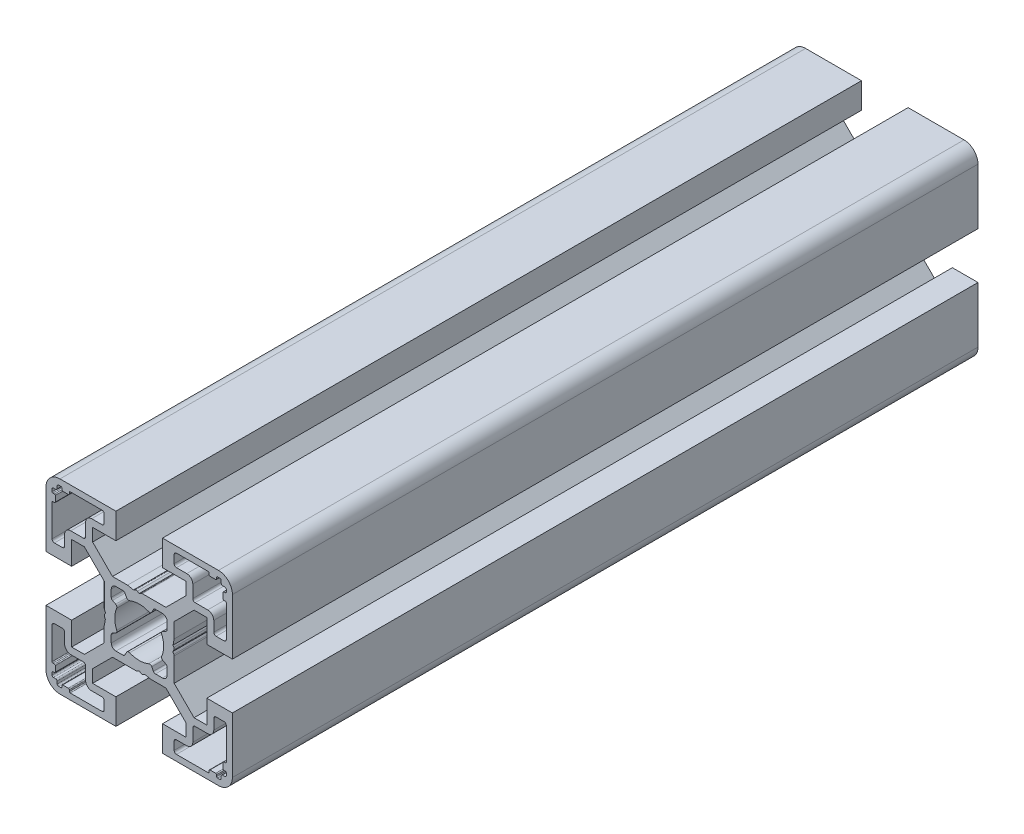
from build123d import *

# Parameters (mm, degrees)
BOSS_EXTRUDE1_DEPTH = 160


with BuildPart() as part:
    # Sketch1 → Boss-Extrude1 (new body)
    with BuildSketch(Plane.XY):
        with BuildLine():
            Line((-11.767766953, -10), (-14.5, -10))
            Line((-14.5, -10), (-14.5, -5))
            Line((-14.5, -5), (-20, -5))
            Line((-20, -5), (-20, -17))
            ThreePointArc((-20, -17), (-19.121320344, -19.121320344), (-17, -20))
            Line((-17, -20), (-5, -20))
            Line((-5, -20), (-5, -14.5))
            Line((-5, -14.5), (-10, -14.5))
            Line((-10, -14.5), (-10, -11.767766953))
            Line((-10, -11.767766953), (-5.732233047, -7.5))
            Line((-5.732233047, -7.5), (-0.653589838, -7.5))
            ThreePointArc((-0.653589838, -7.5), (-0.524180316, -7.482962913), (-0.403589838, -7.433012702))
            Line((-0.403589838, -7.433012702), (0, -7.2))
            Line((0, -7.2), (0.403589838, -7.433012702))
            ThreePointArc((0.403589838, -7.433012702), (0.653589838, -7.5), (0.903589838, -7.433012702))
            Line((0.903589838, -7.433012702), (1.218885629, -7.250976592))
            Line((1.218885629, -7.250976592), (2.5, -7.5))
            Line((2.5, -7.5), (5.732233047, -7.5))
            Line((5.732233047, -7.5), (10, -11.767766953))
            Line((10, -11.767766953), (10, -14.5))
            Line((10, -14.5), (5, -14.5))
            Line((5, -14.5), (5, -20))
            Line((5, -20), (17, -20))
            ThreePointArc((17, -20), (19.121320344, -19.121320344), (20, -17))
            Line((20, -17), (20, -5))
            Line((20, -5), (14.5, -5))
            Line((14.5, -5), (14.5, -10))
            Line((14.5, -10), (11.767766953, -10))
            Line((11.767766953, -10), (7.5, -5.732233047))
            Line((7.5, -5.732233047), (7.5, -0.653589838))
            ThreePointArc((7.5, -0.653589838), (7.482962913, -0.524180316), (7.433012702, -0.403589838))
            Line((7.433012702, -0.403589838), (7.2, 0))
            Line((7.2, 0), (7.433012702, 0.403589838))
            ThreePointArc((7.433012702, 0.403589838), (7.5, 0.653589838), (7.433012702, 0.903589838))
            Line((7.433012702, 0.903589838), (7.250976592, 1.218885629))
            Line((7.250976592, 1.218885629), (7.5, 2.5))
            Line((7.5, 2.5), (7.5, 5.732233047))
            Line((7.5, 5.732233047), (11.767766953, 10))
            Line((11.767766953, 10), (14.5, 10))
            Line((14.5, 10), (14.5, 5))
            Line((14.5, 5), (20, 5))
            Line((20, 5), (20, 17))
            ThreePointArc((20, 17), (19.121320344, 19.121320344), (17, 20))
            Line((17, 20), (5, 20))
            Line((5, 20), (5, 14.5))
            Line((5, 14.5), (10, 14.5))
            Line((10, 14.5), (10, 11.767766953))
            Line((10, 11.767766953), (5.732233047, 7.5))
            Line((5.732233047, 7.5), (0.653589838, 7.5))
            ThreePointArc((0.653589838, 7.5), (0.524180316, 7.482962913), (0.403589838, 7.433012702))
            Line((0.403589838, 7.433012702), (0, 7.2))
            Line((0, 7.2), (-0.403589838, 7.433012702))
            ThreePointArc((-0.403589838, 7.433012702), (-0.653589838, 7.5), (-0.903589838, 7.433012702))
            Line((-0.903589838, 7.433012702), (-1.218885629, 7.250976592))
            Line((-1.218885629, 7.250976592), (-2.5, 7.5))
            Line((-2.5, 7.5), (-5.732233047, 7.5))
            Line((-5.732233047, 7.5), (-10, 11.767766953))
            Line((-10, 11.767766953), (-10, 14.5))
            Line((-10, 14.5), (-5, 14.5))
            Line((-5, 14.5), (-5, 20))
            Line((-5, 20), (-17, 20))
            ThreePointArc((-17, 20), (-19.121320344, 19.121320344), (-20, 17))
            Line((-20, 17), (-20, 5))
            Line((-20, 5), (-14.5, 5))
            Line((-14.5, 5), (-14.5, 10))
            Line((-14.5, 10), (-11.767766953, 10))
            Line((-11.767766953, 10), (-7.5, 5.732233047))
            Line((-7.5, 5.732233047), (-7.5, 0.653589838))
            ThreePointArc((-7.5, 0.653589838), (-7.482962913, 0.524180316), (-7.433012702, 0.403589838))
            Line((-7.433012702, 0.403589838), (-7.2, 0))
            Line((-7.2, 0), (-7.433012702, -0.403589838))
            ThreePointArc((-7.433012702, -0.403589838), (-7.5, -0.653589838), (-7.433012702, -0.903589838))
            Line((-7.433012702, -0.903589838), (-7.250976592, -1.218885629))
            Line((-7.250976592, -1.218885629), (-7.5, -2.5))
            Line((-7.5, -2.5), (-7.5, -5.732233047))
            Line((-7.5, -5.732233047), (-11.767766953, -10))
        make_face()
        with BuildLine():
            Line((7.5, 16.5), (7.5, 18.2))
            ThreePointArc((7.5, 18.2), (7.646446609, 18.553553391), (8, 18.7))
            Line((8, 18.7), (14.8, 18.7))
            ThreePointArc((14.8, 18.7), (14.941421356, 18.641421356), (15, 18.5))
            Line((15, 18.5), (15, 18.2))
            ThreePointArc((15, 18.2), (15.058578644, 18.058578644), (15.2, 18))
            Line((15.2, 18), (16.4, 18))
            ThreePointArc((16.4, 18), (16.541421356, 18.058578644), (16.6, 18.2))
            Line((16.6, 18.2), (16.6, 18.5))
            ThreePointArc((16.6, 18.5), (16.658578644, 18.641421356), (16.8, 18.7))
            Line((16.8, 18.7), (17.3, 18.7))
            ThreePointArc((17.3, 18.7), (17.512132034, 18.612132034), (17.6, 18.4))
            Line((17.6, 18.4), (17.6, 17.9))
            ThreePointArc((17.6, 17.9), (17.687867966, 17.687867966), (17.9, 17.6))
            Line((17.9, 17.6), (18.4, 17.6))
            ThreePointArc((18.4, 17.6), (18.612132034, 17.512132034), (18.7, 17.3))
            Line((18.7, 17.3), (18.7, 16.8))
            ThreePointArc((18.7, 16.8), (18.641421356, 16.658578644), (18.5, 16.6))
            Line((18.5, 16.6), (18.2, 16.6))
            ThreePointArc((18.2, 16.6), (18.058578644, 16.541421356), (18, 16.4))
            Line((18, 16.4), (18, 15.2))
            ThreePointArc((18, 15.2), (18.058578644, 15.058578644), (18.2, 15))
            Line((18.2, 15), (18.5, 15))
            ThreePointArc((18.5, 15), (18.641421356, 14.941421356), (18.7, 14.8))
            Line((18.7, 14.8), (18.7, 8))
            ThreePointArc((18.7, 8), (18.553553391, 7.646446609), (18.2, 7.5))
            Line((18.2, 7.5), (16.5, 7.5))
            ThreePointArc((16.5, 7.5), (16.146446609, 7.646446609), (16, 8))
            Line((16, 8), (16, 10.2))
            ThreePointArc((16, 10.2), (15.619238816, 11.119238816), (14.7, 11.5))
            Line((14.7, 11.5), (12, 11.5))
            ThreePointArc((12, 11.5), (11.646446609, 11.646446609), (11.5, 12))
            Line((11.5, 12), (11.5, 14.7))
            ThreePointArc((11.5, 14.7), (11.119238816, 15.619238816), (10.2, 16))
            Line((10.2, 16), (8, 16))
            ThreePointArc((8, 16), (7.646446609, 16.146446609), (7.5, 16.5))
        make_face(mode=Mode.SUBTRACT)
        with BuildLine():
            Line((14.8, -18.7), (8, -18.7))
            ThreePointArc((8, -18.7), (7.646446609, -18.553553391), (7.5, -18.2))
            Line((7.5, -18.2), (7.5, -16.5))
            ThreePointArc((7.5, -16.5), (7.646446609, -16.146446609), (8, -16))
            Line((8, -16), (10.2, -16))
            ThreePointArc((10.2, -16), (11.119238816, -15.619238816), (11.5, -14.7))
            Line((11.5, -14.7), (11.5, -12))
            ThreePointArc((11.5, -12), (11.646446609, -11.646446609), (12, -11.5))
            Line((12, -11.5), (14.7, -11.5))
            ThreePointArc((14.7, -11.5), (15.619238816, -11.119238816), (16, -10.2))
            Line((16, -10.2), (16, -8))
            ThreePointArc((16, -8), (16.146446609, -7.646446609), (16.5, -7.5))
            Line((16.5, -7.5), (18.2, -7.5))
            ThreePointArc((18.2, -7.5), (18.553553391, -7.646446609), (18.7, -8))
            Line((18.7, -8), (18.7, -14.8))
            ThreePointArc((18.7, -14.8), (18.641421356, -14.941421356), (18.5, -15))
            Line((18.5, -15), (18.2, -15))
            ThreePointArc((18.2, -15), (18.058578644, -15.058578644), (18, -15.2))
            Line((18, -15.2), (18, -16.4))
            ThreePointArc((18, -16.4), (18.058578644, -16.541421356), (18.2, -16.6))
            Line((18.2, -16.6), (18.5, -16.6))
            ThreePointArc((18.5, -16.6), (18.641421356, -16.658578644), (18.7, -16.8))
            Line((18.7, -16.8), (18.7, -17.3))
            ThreePointArc((18.7, -17.3), (18.612132034, -17.512132034), (18.4, -17.6))
            Line((18.4, -17.6), (17.9, -17.6))
            ThreePointArc((17.9, -17.6), (17.687867966, -17.687867966), (17.6, -17.9))
            Line((17.6, -17.9), (17.6, -18.4))
            ThreePointArc((17.6, -18.4), (17.512132034, -18.612132034), (17.3, -18.7))
            Line((17.3, -18.7), (16.8, -18.7))
            ThreePointArc((16.8, -18.7), (16.658578644, -18.641421356), (16.6, -18.5))
            Line((16.6, -18.5), (16.6, -18.2))
            ThreePointArc((16.6, -18.2), (16.541421356, -18.058578644), (16.4, -18))
            Line((16.4, -18), (15.2, -18))
            ThreePointArc((15.2, -18), (15.058578644, -18.058578644), (15, -18.2))
            Line((15, -18.2), (15, -18.5))
            ThreePointArc((15, -18.5), (14.941421356, -18.641421356), (14.8, -18.7))
        make_face(mode=Mode.SUBTRACT)
        with BuildLine():
            Line((-18.7, 16.8), (-18.7, 17.3))
            ThreePointArc((-18.7, 17.3), (-18.612132034, 17.512132034), (-18.4, 17.6))
            Line((-18.4, 17.6), (-17.9, 17.6))
            ThreePointArc((-17.9, 17.6), (-17.687867966, 17.687867966), (-17.6, 17.9))
            Line((-17.6, 17.9), (-17.6, 18.4))
            ThreePointArc((-17.6, 18.4), (-17.512132034, 18.612132034), (-17.3, 18.7))
            Line((-17.3, 18.7), (-16.8, 18.7))
            ThreePointArc((-16.8, 18.7), (-16.658578644, 18.641421356), (-16.6, 18.5))
            Line((-16.6, 18.5), (-16.6, 18.2))
            ThreePointArc((-16.6, 18.2), (-16.541421356, 18.058578644), (-16.4, 18))
            Line((-16.4, 18), (-15.2, 18))
            ThreePointArc((-15.2, 18), (-15.058578644, 18.058578644), (-15, 18.2))
            Line((-15, 18.2), (-15, 18.5))
            ThreePointArc((-15, 18.5), (-14.941421356, 18.641421356), (-14.8, 18.7))
            Line((-14.8, 18.7), (-8, 18.7))
            ThreePointArc((-8, 18.7), (-7.646446609, 18.553553391), (-7.5, 18.2))
            Line((-7.5, 18.2), (-7.5, 16.5))
            ThreePointArc((-7.5, 16.5), (-7.646446609, 16.146446609), (-8, 16))
            Line((-8, 16), (-10.2, 16))
            ThreePointArc((-10.2, 16), (-11.119238816, 15.619238816), (-11.5, 14.7))
            Line((-11.5, 14.7), (-11.5, 12))
            ThreePointArc((-11.5, 12), (-11.646446609, 11.646446609), (-12, 11.5))
            Line((-12, 11.5), (-14.7, 11.5))
            ThreePointArc((-14.7, 11.5), (-15.619238816, 11.119238816), (-16, 10.2))
            Line((-16, 10.2), (-16, 8))
            ThreePointArc((-16, 8), (-16.146446609, 7.646446609), (-16.5, 7.5))
            Line((-16.5, 7.5), (-18.2, 7.5))
            ThreePointArc((-18.2, 7.5), (-18.553553391, 7.646446609), (-18.7, 8))
            Line((-18.7, 8), (-18.7, 14.8))
            ThreePointArc((-18.7, 14.8), (-18.641421356, 14.941421356), (-18.5, 15))
            Line((-18.5, 15), (-18.2, 15))
            ThreePointArc((-18.2, 15), (-18.058578644, 15.058578644), (-18, 15.2))
            Line((-18, 15.2), (-18, 16.4))
            ThreePointArc((-18, 16.4), (-18.058578644, 16.541421356), (-18.2, 16.6))
            Line((-18.2, 16.6), (-18.5, 16.6))
            ThreePointArc((-18.5, 16.6), (-18.641421356, 16.658578644), (-18.7, 16.8))
        make_face(mode=Mode.SUBTRACT)
        with BuildLine():
            Line((-18.7, -14.8), (-18.7, -8))
            ThreePointArc((-18.7, -8), (-18.553553391, -7.646446609), (-18.2, -7.5))
            Line((-18.2, -7.5), (-16.5, -7.5))
            ThreePointArc((-16.5, -7.5), (-16.146446609, -7.646446609), (-16, -8))
            Line((-16, -8), (-16, -10.2))
            ThreePointArc((-16, -10.2), (-15.619238816, -11.119238816), (-14.7, -11.5))
            Line((-14.7, -11.5), (-12, -11.5))
            ThreePointArc((-12, -11.5), (-11.646446609, -11.646446609), (-11.5, -12))
            Line((-11.5, -12), (-11.5, -14.7))
            ThreePointArc((-11.5, -14.7), (-11.119238816, -15.619238816), (-10.2, -16))
            Line((-10.2, -16), (-8, -16))
            ThreePointArc((-8, -16), (-7.646446609, -16.146446609), (-7.5, -16.5))
            Line((-7.5, -16.5), (-7.5, -18.2))
            ThreePointArc((-7.5, -18.2), (-7.646446609, -18.553553391), (-8, -18.7))
            Line((-8, -18.7), (-14.8, -18.7))
            ThreePointArc((-14.8, -18.7), (-14.941421356, -18.641421356), (-15, -18.5))
            Line((-15, -18.5), (-15, -18.2))
            ThreePointArc((-15, -18.2), (-15.058578644, -18.058578644), (-15.2, -18))
            Line((-15.2, -18), (-16.4, -18))
            ThreePointArc((-16.4, -18), (-16.541421356, -18.058578644), (-16.6, -18.2))
            Line((-16.6, -18.2), (-16.6, -18.5))
            ThreePointArc((-16.6, -18.5), (-16.658578644, -18.641421356), (-16.8, -18.7))
            Line((-16.8, -18.7), (-17.3, -18.7))
            ThreePointArc((-17.3, -18.7), (-17.512132034, -18.612132034), (-17.6, -18.4))
            Line((-17.6, -18.4), (-17.6, -17.9))
            ThreePointArc((-17.6, -17.9), (-17.687867966, -17.687867966), (-17.9, -17.6))
            Line((-17.9, -17.6), (-18.4, -17.6))
            ThreePointArc((-18.4, -17.6), (-18.612132034, -17.512132034), (-18.7, -17.3))
            Line((-18.7, -17.3), (-18.7, -16.8))
            ThreePointArc((-18.7, -16.8), (-18.641421356, -16.658578644), (-18.5, -16.6))
            Line((-18.5, -16.6), (-18.2, -16.6))
            ThreePointArc((-18.2, -16.6), (-18.058578644, -16.541421356), (-18, -16.4))
            Line((-18, -16.4), (-18, -15.2))
            ThreePointArc((-18, -15.2), (-18.058578644, -15.058578644), (-18.2, -15))
            Line((-18.2, -15), (-18.5, -15))
            ThreePointArc((-18.5, -15), (-18.641421356, -14.941421356), (-18.7, -14.8))
        make_face(mode=Mode.SUBTRACT)
        with BuildLine():
            Line((-6, 3.490686899), (-6, 5))
            ThreePointArc((-6, 5), (-5.707106781, 5.707106781), (-5, 6))
            Line((-5, 6), (-3.490686899, 6))
            ThreePointArc((-3.490686899, 6), (-3.233167862, 5.92858365), (-3.049213103, 5.734735781))
            Line((-3.049213103, 5.734735781), (-2.689236216, 5.057717724))
            ThreePointArc((-2.689236216, 5.057717724), (-2.414618721, 4.821116073), (-2.052304818, 4.832240157))
            ThreePointArc((-2.052304818, 4.832240157), (0, 5.25), (2.052304818, 4.832240157))
            ThreePointArc((2.052304818, 4.832240157), (2.414618721, 4.821116073), (2.689236216, 5.057717724))
            Line((2.689236216, 5.057717724), (3.049213103, 5.734735781))
            ThreePointArc((3.049213103, 5.734735781), (3.233167862, 5.92858365), (3.490686899, 6))
            Line((3.490686899, 6), (5, 6))
            ThreePointArc((5, 6), (5.707106781, 5.707106781), (6, 5))
            Line((6, 5), (6, 3.490686899))
            ThreePointArc((6, 3.490686899), (5.92858365, 3.233167862), (5.734735781, 3.049213103))
            Line((5.734735781, 3.049213103), (5.057717724, 2.689236216))
            ThreePointArc((5.057717724, 2.689236216), (4.821116073, 2.414618721), (4.832240157, 2.052304818))
            ThreePointArc((4.832240157, 2.052304818), (5.25, 0), (4.832240157, -2.052304818))
            ThreePointArc((4.832240157, -2.052304818), (4.821116073, -2.414618721), (5.057717724, -2.689236216))
            Line((5.057717724, -2.689236216), (5.734735781, -3.049213103))
            ThreePointArc((5.734735781, -3.049213103), (5.92858365, -3.233167862), (6, -3.490686899))
            Line((6, -3.490686899), (6, -5))
            ThreePointArc((6, -5), (5.707106781, -5.707106781), (5, -6))
            Line((5, -6), (3.490686899, -6))
            ThreePointArc((3.490686899, -6), (3.233167862, -5.92858365), (3.049213103, -5.734735781))
            Line((3.049213103, -5.734735781), (2.689236216, -5.057717724))
            ThreePointArc((2.689236216, -5.057717724), (2.414618721, -4.821116073), (2.052304818, -4.832240157))
            ThreePointArc((2.052304818, -4.832240157), (0, -5.25), (-2.052304818, -4.832240157))
            ThreePointArc((-2.052304818, -4.832240157), (-2.414618721, -4.821116073), (-2.689236216, -5.057717724))
            Line((-2.689236216, -5.057717724), (-3.049213103, -5.734735781))
            ThreePointArc((-3.049213103, -5.734735781), (-3.233167862, -5.92858365), (-3.490686899, -6))
            Line((-3.490686899, -6), (-5, -6))
            ThreePointArc((-5, -6), (-5.707106781, -5.707106781), (-6, -5))
            Line((-6, -5), (-6, -3.490686899))
            ThreePointArc((-6, -3.490686899), (-5.92858365, -3.233167862), (-5.734735781, -3.049213103))
            Line((-5.734735781, -3.049213103), (-5.057717724, -2.689236216))
            ThreePointArc((-5.057717724, -2.689236216), (-4.821116073, -2.414618721), (-4.832240157, -2.052304818))
            ThreePointArc((-4.832240157, -2.052304818), (-5.25, 0), (-4.832240157, 2.052304818))
            ThreePointArc((-4.832240157, 2.052304818), (-4.821116073, 2.414618721), (-5.057717724, 2.689236216))
            Line((-5.057717724, 2.689236216), (-5.734735781, 3.049213103))
            ThreePointArc((-5.734735781, 3.049213103), (-5.92858365, 3.233167862), (-6, 3.490686899))
        make_face(mode=Mode.SUBTRACT)
    extrude(amount=-BOSS_EXTRUDE1_DEPTH)


solid = part.part
